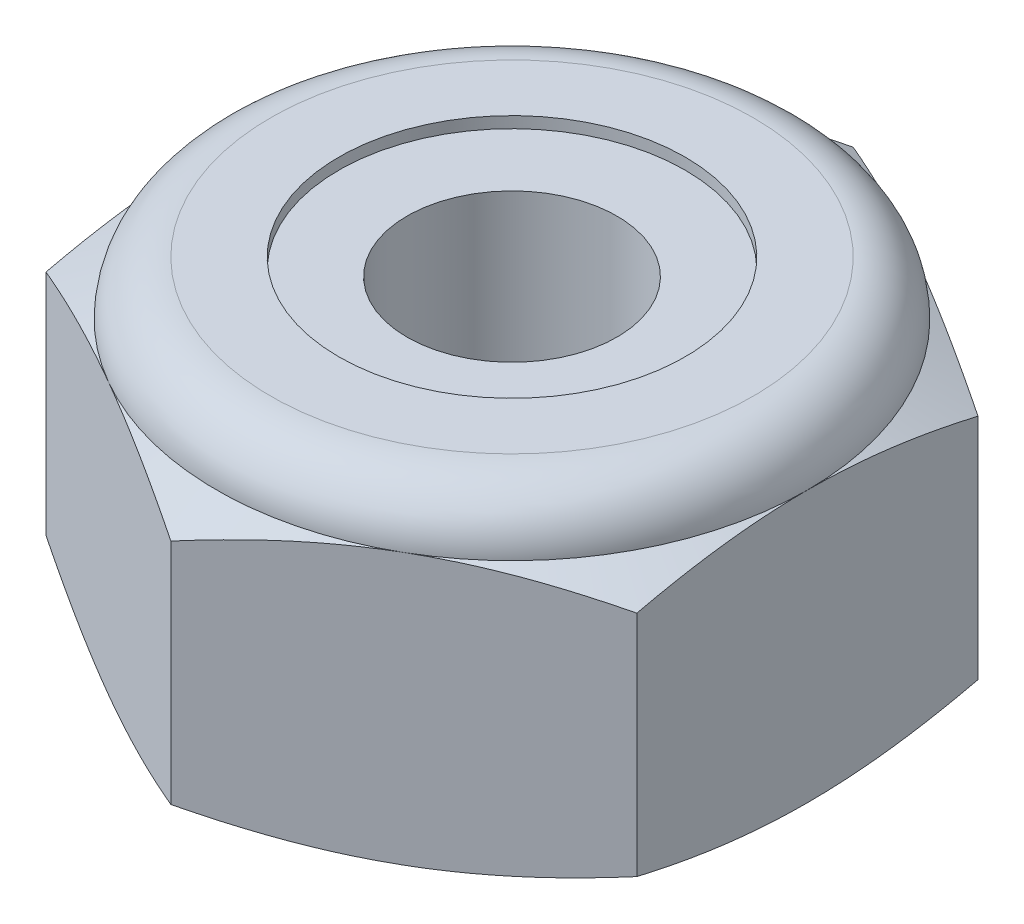
from build123d import *

# Parameters (mm, degrees)
EXTRUDE1_DEPTH      = 4.365625
SKETCH2_W           = 1.7526
SKETCH2_H           = 4.365625
LPATTERN1_COUNT     = 6
LPATTERN1_PITCH     = 0.79375
LPATTERN1_COL_COUNT = 2
LPATTERN1_COL_PITCH = 0.79375
SKETCH8_R           = 1.613475607
SKETCH8_R_2         = 1.410275607
BOSS_EXTRUDE1_DEPTH = 4.137025


with BuildPart() as part:
    # Sketch1 → Extrude1 (new body)
    with BuildSketch(Plane(origin=(0, 0, 0), x_dir=(1, 0, 0), z_dir=(0, 1, 0))):
        Polygon((0, 4.582717762), (-3.96875, 2.291358881), (-3.96875, -2.291358881), (0, -4.582717762), (3.96875, -2.291358881), (3.96875, 2.291358881), align=None)
    extrude(amount=EXTRUDE1_DEPTH)

    # Sketch4 → Cut-Revolve2 (revolve, cut)
    with BuildSketch(Plane(origin=(0, 0, 0), x_dir=(0, 0, -1), z_dir=(1, 0, 0))):
        Polygon((0, 4.365625), (1.7526, 4.365625), (1.410275607, 4.205996514), (1.410275607, 0.159628486), (1.7526, 0), (0, 0), align=None)
    revolve(axis=Axis((0, 4.365625, 0), (0, 1, 0)), mode=Mode.SUBTRACT)


with BuildPart() as body_2:
    # Sketch2 → Revolve1 (revolve)
    with BuildSketch(Plane(origin=(0, 0, 0), x_dir=(0, 0, -1), z_dir=(1, 0, 0))):
        with Locations((0.8763, 2.1828125)):
            Rectangle(SKETCH2_W, SKETCH2_H)
    revolve(axis=Axis((0, -1.7526, 0), (0, 1, 0)))

    # Sketch3 → Cut-Revolve1 (revolve, cut)
    with BuildSketch(Plane(origin=(0, 0, 0), x_dir=(0, 0, -1), z_dir=(1, 0, 0))):
        Polygon((1.774513192, 4.268856346), (1.927905533, 3.591475768), (1.454101991, 3.7385105), (1.410275607, 3.932047808), align=None)
    cut_revolve1 = revolve(axis=Axis((0, 4.365625, 0.193538035), (0, -0.975306119, -0.220857364)), mode=Mode.SUBTRACT)

    # LPattern1: Cut-Revolve1 ×6
    with Locations(*[(0, -i * LPATTERN1_PITCH, 0) for i in range(1, LPATTERN1_COUNT)]):
        add(cut_revolve1, mode=Mode.SUBTRACT)

    # LPattern1 col: Cut-Revolve1 ×2
    with Locations(*[(0, i * LPATTERN1_COL_PITCH, 0) for i in range(1, LPATTERN1_COL_COUNT)]):
        add(cut_revolve1, mode=Mode.SUBTRACT)


with BuildPart() as part_1:
    add(part.part)

    # Combine1: cut body 2
    add(body_2.part, mode=Mode.SUBTRACT)

    # Sketch5 → Cut-Revolve3 (revolve, cut)
    with BuildSketch(Plane(origin=(0, 0, 0), x_dir=(0, 0, -1), z_dir=(1, 0, 0))):
        with BuildLine():
            Line((0, 0), (3.96875, 0))
            Line((3.96875, 0), (4.582717762, 0.286297869))
            Line((4.582717762, 0.286297869), (4.582717762, 3.351722964))
            Line((4.582717762, 3.351722964), (3.96875, 3.638020833))
            ThreePointArc((3.96875, 3.638020833), (3.755639674, 4.152514674), (3.241145833, 4.365625))
            Line((3.241145833, 4.365625), (3.241145833, 5.635625))
            Line((3.241145833, 5.635625), (5.852717762, 5.635625))
            Line((5.852717762, 5.635625), (5.852717762, -1.27))
            Line((5.852717762, -1.27), (0, -1.27))
            Line((0, -1.27), (0, 0))
        make_face()
    revolve(axis=Axis((0, 0, 0), (0, 1, 0)), mode=Mode.SUBTRACT)

    # Sketch6 → Cut-Revolve4 (revolve, cut)
    with BuildSketch(Plane(origin=(0, 0, 0), x_dir=(0, 0, -1), z_dir=(1, 0, 0))):
        with BuildLine():
            Line((0, 3.638020833), (3.81635, 3.638020833))
            ThreePointArc((3.81635, 3.638020833), (3.6478766, 4.0447516), (3.241145833, 4.213225))
            Line((3.241145833, 4.213225), (2.32571072, 4.213225))
            Line((2.32571072, 4.213225), (2.32571072, 5.635625))
            Line((2.32571072, 5.635625), (0, 5.635625))
            Line((0, 5.635625), (0, 3.638020833))
        make_face()
    revolve(axis=Axis((0, 5.635625, 0), (0, 1, 0)), mode=Mode.SUBTRACT)



with BuildPart() as body_2_2:
    # Sketch7 → Revolve2 (revolve)
    with BuildSketch(Plane(origin=(0, 0, 0), x_dir=(0, 0, -1), z_dir=(1, 0, 0))):
        with BuildLine():
            Line((1.410275607, 3.714220833), (3.734297654, 3.714220833))
            ThreePointArc((3.734297654, 3.714220833), (3.565938876, 4.016854092), (3.241145833, 4.137025))
            Line((3.241145833, 4.137025), (1.410275607, 4.137025))
            Line((1.410275607, 4.137025), (1.410275607, 3.714220833))
        make_face()
    revolve(axis=Axis((0, 3.714220833, 0), (0, 1, 0)))


with BuildPart() as part_2:
    add(part_1.part)

    add(body_2_2.part)  # Boss-Extrude1 merges body 2 2
    # Sketch8 → Boss-Extrude1 (add)
    with BuildSketch(Plane(origin=(0, 4.137025, 0), x_dir=(1, 0, 0), z_dir=(0, 1, 0))):
        Circle(SKETCH8_R)
        Circle(SKETCH8_R_2, mode=Mode.SUBTRACT)
    extrude(amount=-BOSS_EXTRUDE1_DEPTH)


solid = part_2.part
